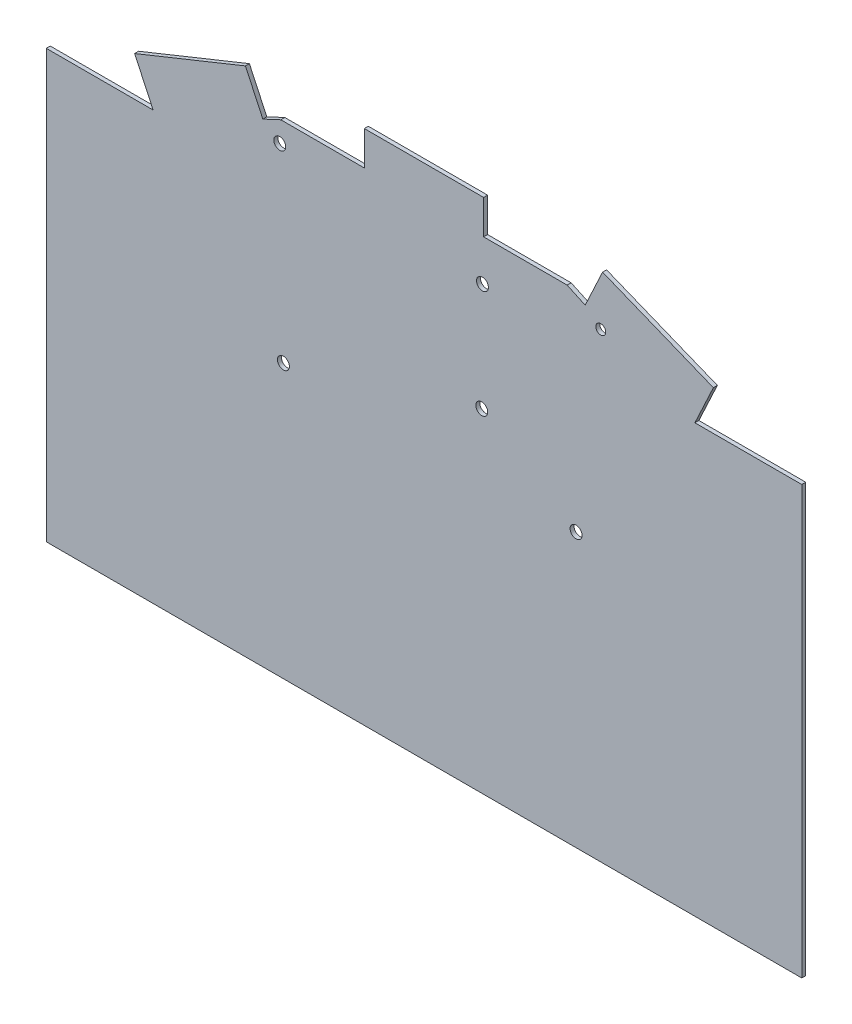
from build123d import *

# Parameters (mm, degrees)
CROQUIS1_W              = 190
CROQUIS1_H              = 130
SALIENTE_EXTRUIR1_DEPTH = 1
CROQUIS9_R              = 1.25
CROQUIS9_R_2            = 1.5
CORTAR_EXTRUIR2_DEPTH   = 10
CORTAR_EXTRUIR3_REACH   = 3
CORTAR_EXTRUIR4_REACH   = 3


with BuildPart() as part:
    # Croquis1 → Saliente-Extruir1 (new body)
    with BuildSketch(Plane.XY):
        Rectangle(CROQUIS1_W, CROQUIS1_H)
    extrude(amount=SALIENTE_EXTRUIR1_DEPTH)

    # Croquis9 → Cortar-Extruir2 (cut)
    with BuildSketch(Plane(origin=(0, 0, 0), x_dir=(-1, 0, 0), z_dir=(0, 0, -1))):
        with Locations((-44.45, 51)):
            Circle(CROQUIS9_R)
        with Locations((35.357472454, 3.746718702)):
            Circle(CROQUIS9_R_2)
        with Locations((36.270123649, 51.127714796)):
            Circle(CROQUIS9_R_2)
        with Locations((-14.524931807, 18.747519864)):
            Circle(CROQUIS9_R_2)
        with Locations((-14.700351259, 45.987329572)):
            Circle(CROQUIS9_R_2)
        with Locations((-38.24, 3.75)):
            Circle(CROQUIS9_R_2)
    extrude(amount=-CORTAR_EXTRUIR2_DEPTH, mode=Mode.SUBTRACT)

    # Croquis12 → Cortar-Extruir3 (cut, up to next)
    with BuildSketch(Plane(origin=(0, 0, 0), x_dir=(-1, 0, 0), z_dir=(0, 0, -1)), mode=Mode.PRIVATE) as cortar_extruir3_sk1:
        Polygon((-95, 65), (-95, 43.5), (-41.651647359, 65), align=None)
    cortar_extruir3_tool1 = extrude(cortar_extruir3_sk1.sketch, amount=-CORTAR_EXTRUIR3_REACH, mode=Mode.PRIVATE) & part.part
    add(cortar_extruir3_tool1.solids().sort_by_distance((77.217216, 57.833333, 0))[0], mode=Mode.SUBTRACT)
    # Croquis12 → Cortar-Extruir3 (cut, up to next)
    with BuildSketch(Plane(origin=(0, 0, 0), x_dir=(-1, 0, 0), z_dir=(0, 0, -1)), mode=Mode.PRIVATE) as cortar_extruir3_sk2:
        Polygon((41.651647359, 65), (95, 65), (95, 43.5), align=None)
    cortar_extruir3_tool2 = extrude(cortar_extruir3_sk2.sketch, amount=-CORTAR_EXTRUIR3_REACH, mode=Mode.PRIVATE) & part.part
    add(cortar_extruir3_tool2.solids().sort_by_distance((-77.217216, 57.833333, 0))[0], mode=Mode.SUBTRACT)

    # Croquis13 → Cortar-Extruir4 (cut, up to next)
    with BuildSketch(Plane(origin=(0, 0, 0), x_dir=(-1, 0, 0), z_dir=(0, 0, -1)), mode=Mode.PRIVATE) as cortar_extruir4_sk1:
        Polygon((-68.123188454, 42.482226287), (-72.77455345, 52.45711071), (-95, 43.5), (-95.030741331, 42.482226287), align=None)
    cortar_extruir4_tool1 = extrude(cortar_extruir4_sk1.sketch, amount=-CORTAR_EXTRUIR4_REACH, mode=Mode.PRIVATE) & part.part
    add(cortar_extruir4_tool1.solids().sort_by_distance((79.331365, 45.833261, 0))[0], mode=Mode.SUBTRACT)
    # Croquis13 → Cortar-Extruir4 (cut, up to next)
    with BuildSketch(Plane(origin=(0, 0, 0), x_dir=(-1, 0, 0), z_dir=(0, 0, -1)), mode=Mode.PRIVATE) as cortar_extruir4_sk2:
        Polygon((-44.909770717, 63.686938795), (-40.531538935, 54.297790439), (-36, 56.410881748), (-15, 56.410881748), (-15, 65), (-41.651647359, 65), align=None)
    cortar_extruir4_tool2 = extrude(cortar_extruir4_sk2.sketch, amount=-CORTAR_EXTRUIR4_REACH, mode=Mode.PRIVATE) & part.part
    add(cortar_extruir4_tool2.solids().sort_by_distance((29.368606, 60.647773, 0))[0], mode=Mode.SUBTRACT)
    # Croquis13 → Cortar-Extruir4 (cut, up to next)
    with BuildSketch(Plane(origin=(0, 0, 0), x_dir=(-1, 0, 0), z_dir=(0, 0, -1)), mode=Mode.PRIVATE) as cortar_extruir4_sk3:
        Polygon((44.909770717, 63.686938795), (41.651647359, 65), (15.011500088, 65), (15, 56.410881748), (36, 56.410881748), (40.531538935, 54.297790439), align=None)
    cortar_extruir4_tool3 = extrude(cortar_extruir4_sk3.sketch, amount=-CORTAR_EXTRUIR4_REACH, mode=Mode.PRIVATE) & part.part
    add(cortar_extruir4_tool3.solids().sort_by_distance((-29.371465, 60.647477, 0))[0], mode=Mode.SUBTRACT)
    # Croquis13 → Cortar-Extruir4 (cut, up to next)
    with BuildSketch(Plane(origin=(0, 0, 0), x_dir=(-1, 0, 0), z_dir=(0, 0, -1)), mode=Mode.PRIVATE) as cortar_extruir4_sk4:
        Polygon((72.77455345, 52.45711071), (68.123188454, 42.482226287), (95, 42.482226287), (95, 43.5), align=None)
    cortar_extruir4_tool4 = extrude(cortar_extruir4_sk4.sketch, amount=-CORTAR_EXTRUIR4_REACH, mode=Mode.PRIVATE) & part.part
    add(cortar_extruir4_tool4.solids().sort_by_distance((-79.329677, 45.833585, 0))[0], mode=Mode.SUBTRACT)


solid = part.part
